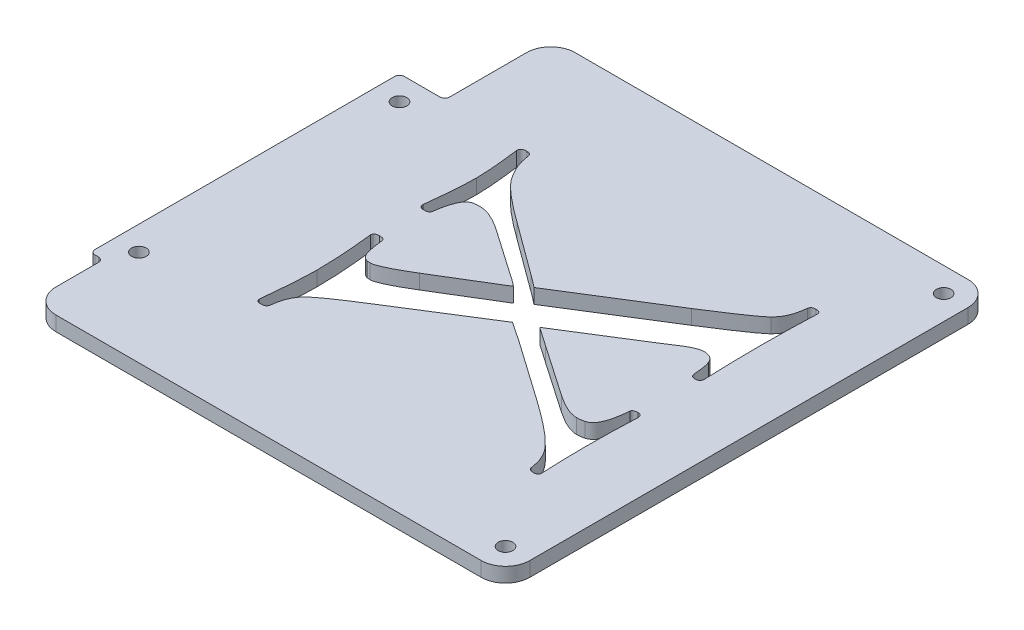
from build123d import *

# Parameters (mm, degrees)
BOSS_EXTRUDE1_DEPTH = 3
FILLET3_R           = 5
FILLET2_R           = 1
SKETCH2_R           = 1.5
CUT_EXTRUDE1_DEPTH  = 3
CUT_EXTRUDE2_DEPTH  = 3


with BuildPart() as part:
    # Sketch1 → Boss-Extrude1 (new body)
    with BuildSketch(Plane(origin=(0, 23, 0), x_dir=(1, 0, 0), z_dir=(0, 1, 0))):
        Polygon((98.305417602, 50), (98.305417602, 28.219474586), (89, 28.219474586), (89, -35.308001182), (91.659783805, -35.308001182), (91.659783805, -50), (97.650210801, -50), (189, -50), (189, 50), align=None)
    extrude(amount=BOSS_EXTRUDE1_DEPTH)

    # Fillet3
    fillet3_edges = [part.edges().sort_by_distance(p)[0] for p in [
        (189, 24.5, 50),
        (91.659783805, 24.5, 50),
        (98.305417602, 24.5, -50),
        (189, 24.5, -50),
    ]]
    fillet(fillet3_edges, radius=FILLET3_R)

    # Fillet2
    fillet2_edges = [part.edges().sort_by_distance(p)[0] for p in [
        (91.659783805, 24.5, 35.308001182),
        (89, 24.5, 35.308001182),
        (89, 24.5, -28.219474586),
        (98.305417602, 24.5, -28.219474586),
    ]]
    fillet(fillet2_edges, radius=FILLET2_R)

    # Sketch2 → Cut-Extrude1 (cut)
    with BuildSketch(Plane(origin=(0, 23, 0), x_dir=(1, 0, 0), z_dir=(0, 1, 0))):
        with Locations((184, -45)):
            Circle(SKETCH2_R)
        with Locations((94, -30.308001182)):
            Circle(SKETCH2_R)
        with Locations((94, 23.219474586)):
            Circle(SKETCH2_R)
        with Locations((184, 45)):
            Circle(SKETCH2_R)
    extrude(amount=CUT_EXTRUDE1_DEPTH, mode=Mode.SUBTRACT)

    # Sketch4 → Cut-Extrude2 (cut)
    with BuildSketch(Plane(origin=(0, 23, 0), x_dir=(1, 0, 0), z_dir=(0, 1, 0))):
        with BuildLine():
            Line((144.836538462, -4.405002967), (127.949519231, -15.042022198))
            add(Edge.make_bspline(
                [(127.949519231, -15.042022198), (127.383127553, -15.392246735), (126.301581574, -16.061013517), (124.782941164, -17.050886016), (123.413502397, -17.937550274), (122.221392395, -18.755591493), (121.177972607, -19.471486976), (120.314913735, -20.120669627), (119.610681433, -20.683215798), (119.210091774, -21.045947399), (119.03125, -21.207887583)],
                knots=[0, 0, 0, 0, 0.001997689, 0.003814661, 0.005438147, 0.006891629, 0.008151988, 0.009233719, 0.010130985, 0.010854638, 0.010854638, 0.010854638, 0.010854638], degree=3))
            add(Edge.make_bspline(
                [(119.03125, -21.207887583), (118.748201115, -21.52191014), (118.168801385, -22.164712831), (117.5545606, -23.367577881), (117.096940223, -24.745013365), (116.970362975, -25.743352665), (116.903846154, -26.267983736)],
                knots=[0, 0, 0, 0, 0.001263449, 0.002586275, 0.004015401, 0.005598156, 0.005598156, 0.005598156, 0.005598156], degree=3))
            add(Edge.make_bspline(
                [(116.903846154, -26.267983736), (116.872872765, -26.380485447), (116.813744298, -26.595252187), (116.565778181, -26.857180094), (116.195478928, -26.9748707), (115.922777734, -26.991879637), (115.774038462, -27.001156813)],
                knots=[0, 0, 0, 0, 0.000346062, 0.000660635, 0.001033425, 0.001480728, 0.001480728, 0.001480728, 0.001480728], degree=3))
            add(Edge.make_bspline(
                [(115.774038462, -27.001156813), (115.615840619, -26.999292557), (115.335974003, -26.995994514), (114.986148077, -26.864071662), (114.727918889, -26.653061509), (114.704405221, -26.454352171), (114.692307692, -26.352118352)],
                knots=[0, 0, 0, 0, 0.000470135, 0.000831712, 0.001112304, 0.001409643, 0.001409643, 0.001409643, 0.001409643], degree=3))
            add(Edge.make_bspline(
                [(114.692307692, -26.352118352), (114.753110505, -25.731192556), (114.869978219, -24.537725092), (115.027629344, -22.811043643), (115.159831841, -21.216431706), (115.268078948, -19.754038379), (115.353651644, -18.427912295), (115.414445517, -17.23393227), (115.453050203, -16.172085521), (115.458849243, -15.506792147), (115.461538462, -15.198272198)],
                knots=[0, 0, 0, 0, 0.001871684, 0.003597522, 0.005201538, 0.006671868, 0.007996658, 0.009188078, 0.010258397, 0.011183956, 0.011183956, 0.011183956, 0.011183956], degree=3))
            add(Edge.make_bspline(
                [(115.461538462, -15.198272198), (115.451286198, -14.352743878), (115.429651229, -12.568457125), (115.273718397, -9.755087799), (115.034984439, -6.665181967), (114.809821171, -4.516691888), (114.692307692, -3.395387583)],
                knots=[0, 0, 0, 0, 0.002536513, 0.005352709, 0.008450991, 0.011833161, 0.011833161, 0.011833161, 0.011833161], degree=3))
            add(Edge.make_bspline(
                [(114.692307692, -3.395387583), (114.704437153, -3.282548355), (114.727747275, -3.065696499), (114.970876174, -2.807073443), (115.342975667, -2.682888604), (115.624840109, -2.669736878), (115.786057692, -2.662214506)],
                knots=[0, 0, 0, 0, 0.000332435, 0.000638867, 0.001000444, 0.001483611, 0.001483611, 0.001483611, 0.001483611], degree=3))
            add(Edge.make_bspline(
                [(115.786057692, -2.662214506), (115.939656908, -2.666597614), (116.211768647, -2.674362596), (116.561756556, -2.781865744), (116.832507103, -2.95469515), (116.896246922, -3.136752797), (116.927884615, -3.227118352)],
                knots=[0, 0, 0, 0, 0.000458152, 0.000811648, 0.001095312, 0.001374872, 0.001374872, 0.001374872, 0.001374872], degree=3))
            add(Edge.make_bspline(
                [(116.927884615, -3.227118352), (116.982849031, -3.671982018), (117.082001591, -4.474489789), (117.23002735, -5.551059507), (117.388710401, -6.367065066), (117.522406295, -6.817488836), (117.576923077, -7.001156813)],
                knots=[0, 0, 0, 0, 0.001344704, 0.002425767, 0.003260217, 0.003834756, 0.003834756, 0.003834756, 0.003834756], degree=3))
            add(Edge.make_bspline(
                [(117.576923077, -7.001156813), (117.648507033, -7.178202401), (117.785626495, -7.517334195), (118.122152571, -7.934591169), (118.528360995, -8.253438433), (118.846637322, -8.363764981), (119.007211538, -8.419426044)],
                knots=[0, 0, 0, 0, 0.000569995, 0.001091829, 0.001589431, 0.002096096, 0.002096096, 0.002096096, 0.002096096], degree=3))
            add(Edge.make_bspline(
                [(119.007211538, -8.419426044), (119.115236434, -8.43344845), (119.330699129, -8.461417053), (119.547930348, -8.465478018), (119.65625, -8.467502967)],
                knots=[0, 0, 0, 0, 0.000326516, 0.000651258, 0.000651258, 0.000651258, 0.000651258], degree=3))
            add(Edge.make_bspline(
                [(119.65625, -8.467502967), (119.80138086, -8.45638107), (120.138041343, -8.430581573), (120.689465078, -8.250909029), (121.366329192, -8.002753917), (122.154525275, -7.626516985), (123.087681364, -7.193065113), (124.124218267, -6.616881611), (125.29176971, -5.958831664), (126.103552637, -5.476455961), (126.53125, -5.222310659)],
                knots=[0, 0, 0, 0, 0.000435355, 0.001009894, 0.001728741, 0.002600114, 0.003626897, 0.004815404, 0.006155643, 0.007648061, 0.007648061, 0.007648061, 0.007648061], degree=3))
            Line((126.53125, -5.222310659), (138.538461538, 2.085381648))
            add(Edge.make_bspline(
                [(138.538461538, 2.085381648), (138.110471753, 2.428371758), (137.194007507, 3.162824268), (136.212856357, 3.808529268), (135.689903846, 4.152689341)],
                knots=[0, 0, 0, 0, 0.001644484, 0.00352137, 0.00352137, 0.00352137, 0.00352137], degree=3))
            Line((135.689903846, 4.152689341), (126.206730769, 10.727208571))
            add(Edge.make_bspline(
                [(126.206730769, 10.727208571), (125.695873286, 11.050460946), (124.745448532, 11.651855797), (123.335727312, 12.333795342), (122.065583026, 12.770656194), (121.253420745, 12.836525319), (120.882211538, 12.866631648)],
                knots=[0, 0, 0, 0, 0.001811877, 0.003370906, 0.004693786, 0.005807431, 0.005807431, 0.005807431, 0.005807431], degree=3))
            add(Edge.make_bspline(
                [(120.882211538, 12.866631648), (120.65322679, 12.860419876), (120.172300681, 12.847373578), (119.699570737, 12.75747602), (119.451923077, 12.710381648)],
                knots=[0, 0, 0, 0, 0.000686044, 0.001440867, 0.001440867, 0.001440867, 0.001440867], degree=3))
            add(Edge.make_bspline(
                [(119.451923077, 12.710381648), (119.299807708, 12.64937105), (118.980247873, 12.521201642), (118.553357151, 12.167626018), (118.182630845, 11.674411308), (117.861509743, 11.043719136), (117.564789055, 10.286993292), (117.300047417, 9.391108691), (117.09079131, 8.35647488), (116.984153061, 7.618833988), (116.927884615, 7.229612417)],
                knots=[0, 0, 0, 0, 0.000489406, 0.00102813, 0.001636379, 0.002329963, 0.003144615, 0.004072512, 0.005128564, 0.006308287, 0.006308287, 0.006308287, 0.006308287], degree=3))
            add(Edge.make_bspline(
                [(116.927884615, 7.229612417), (116.901872489, 7.112745653), (116.852062547, 6.888960539), (116.610235786, 6.629167127), (116.269746741, 6.478578705), (116.012237425, 6.466850862), (115.870192308, 6.460381648)],
                knots=[0, 0, 0, 0, 0.000353496, 0.000676901, 0.001021079, 0.00144449, 0.00144449, 0.00144449, 0.00144449], degree=3))
            add(Edge.make_bspline(
                [(115.870192308, 6.460381648), (115.695328233, 6.463299781), (115.386414272, 6.468454939), (114.993265039, 6.645053538), (114.721020008, 6.934658897), (114.702138587, 7.183949923), (114.692307692, 7.313747033)],
                knots=[0, 0, 0, 0, 0.000519058, 0.000916966, 0.001266351, 0.001645862, 0.001645862, 0.001645862, 0.001645862], degree=3))
            add(Edge.make_bspline(
                [(114.692307692, 7.313747033), (114.753349078, 7.854508859), (114.871761588, 8.903517889), (115.028776168, 10.433970874), (115.160140859, 11.86842069), (115.269619425, 13.206542418), (115.354496528, 14.444607976), (115.414901751, 15.586548033), (115.453615309, 16.632388141), (115.458984116, 17.297692402), (115.461538462, 17.614227802)],
                knots=[0, 0, 0, 0, 0.001632581, 0.003167, 0.004615355, 0.005953868, 0.007194704, 0.008338111, 0.009384406, 0.010334001, 0.010334001, 0.010334001, 0.010334001], degree=3))
            add(Edge.make_bspline(
                [(115.461538462, 17.614227802), (115.45893556, 17.874678434), (115.453407278, 18.427847421), (115.414472387, 19.305427434), (115.354006311, 20.279095234), (115.269072316, 21.34888522), (115.15943248, 22.518702864), (115.028373847, 23.784925284), (114.870231921, 25.150965033), (114.753128782, 26.091880692), (114.692307692, 26.580573956)],
                knots=[0, 0, 0, 0, 0.000781342, 0.001659487, 0.002634898, 0.003707913, 0.004878786, 0.006159666, 0.007526797, 0.009004185, 0.009004185, 0.009004185, 0.009004185], degree=3))
            add(Edge.make_bspline(
                [(114.692307692, 26.580573956), (114.702509868, 26.721020585), (114.721990872, 26.989202725), (114.978605259, 27.322573749), (115.389116261, 27.494156335), (115.696188965, 27.509423045), (115.870192308, 27.518073956)],
                knots=[0, 0, 0, 0, 0.000414968, 0.00079238, 0.001190287, 0.001710596, 0.001710596, 0.001710596, 0.001710596], degree=3))
            add(Edge.make_bspline(
                [(115.870192308, 27.518073956), (116.011883571, 27.507387883), (116.275462267, 27.487509301), (116.637972816, 27.316869106), (116.853037271, 26.978814056), (116.893940076, 26.719548958), (116.915865385, 26.580573956)],
                knots=[0, 0, 0, 0, 0.000424944, 0.000790495, 0.001153865, 0.001573679, 0.001573679, 0.001573679, 0.001573679], degree=3))
            add(Edge.make_bspline(
                [(116.915865385, 26.580573956), (117.001281169, 26.08799141), (117.176295173, 25.078706715), (117.734892637, 23.58987962), (118.487877879, 22.073780289), (119.154299543, 21.115918163), (119.5, 20.619035494)],
                knots=[0, 0, 0, 0, 0.001496817, 0.003066926, 0.00474936, 0.006562831, 0.006562831, 0.006562831, 0.006562831], degree=3))
            add(Edge.make_bspline(
                [(119.5, 20.619035494), (119.677478367, 20.408141742), (120.057531979, 19.956532155), (120.73372047, 19.284099273), (121.51907404, 18.541873374), (122.443997138, 17.748043668), (123.486635789, 16.882553452), (124.661279522, 15.961198449), (125.966699477, 14.989096948), (126.875455044, 14.32048406), (127.348557692, 13.972400879)],
                knots=[0, 0, 0, 0, 0.000826535, 0.001769949, 0.002858337, 0.004068166, 0.005425488, 0.006923463, 0.008546059, 0.010308137, 0.010308137, 0.010308137, 0.010308137], degree=3))
            Line((127.348557692, 13.972400879), (138.141826923, 6.051727802))
            add(Edge.make_bspline(
                [(138.141826923, 6.051727802), (138.573726766, 5.743444252), (139.497712665, 5.083917146), (140.377569534, 4.366496146), (140.846153846, 3.98442011)],
                knots=[0, 0, 0, 0, 0.001591493, 0.003404765, 0.003404765, 0.003404765, 0.003404765], degree=3))
            Line((140.846153846, 3.98442011), (160.774038462, 16.436343187))
            add(Edge.make_bspline(
                [(160.774038462, 16.436343187), (161.423572659, 16.852246648), (162.656151068, 17.641479346), (164.397698299, 18.773176707), (165.940071931, 19.775082238), (167.255263967, 20.678996589), (168.366026365, 21.445268828), (169.262782898, 22.094547837), (169.946295257, 22.630622941), (170.32618387, 22.957744074), (170.485576923, 23.094997033)],
                knots=[0, 0, 0, 0, 0.002313819, 0.004390782, 0.006230942, 0.007831125, 0.009178138, 0.010279194, 0.011152058, 0.011783039, 0.011783039, 0.011783039, 0.011783039], degree=3))
            add(Edge.make_bspline(
                [(170.485576923, 23.094997033), (170.776838011, 23.429099085), (171.369405188, 24.108825688), (172.003193088, 25.364560381), (172.452749205, 26.798429222), (172.581625507, 27.831209773), (172.649038462, 28.371439341)],
                knots=[0, 0, 0, 0, 0.001325226, 0.002696156, 0.004182513, 0.005812747, 0.005812747, 0.005812747, 0.005812747], degree=3))
            add(Edge.make_bspline(
                [(172.649038462, 28.371439341), (172.671748766, 28.479616779), (172.715743585, 28.689180106), (172.947424692, 28.94454591), (173.295923022, 29.067591071), (173.553677557, 29.083751037), (173.694711538, 29.092593187)],
                knots=[0, 0, 0, 0, 0.000326958, 0.00063339, 0.000983808, 0.001407219, 0.001407219, 0.001407219, 0.001407219], degree=3))
            add(Edge.make_bspline(
                [(173.694711538, 29.092593187), (173.840069372, 29.084747589), (174.098719582, 29.070787107), (174.442219482, 28.943800376), (174.6668533, 28.68939339), (174.683644356, 28.479654173), (174.692307692, 28.371439341)],
                knots=[0, 0, 0, 0, 0.000435355, 0.000774672, 0.001073224, 0.00139145, 0.00139145, 0.00139145, 0.00139145], degree=3))
            add(Edge.make_bspline(
                [(174.692307692, 28.371439341), (174.622199026, 26.488640924), (174.4838024, 22.771939943), (174.462455908, 19.052732497), (174.451923077, 17.217593187)],
                knots=[0, 0, 0, 0, 0.005651915, 0.01115705, 0.01115705, 0.01115705, 0.01115705], degree=3))
            add(Edge.make_bspline(
                [(174.451923077, 17.217593187), (174.45288042, 16.147853356), (174.454755771, 14.052327372), (174.509057658, 10.975395797), (174.57341806, 8.026167011), (174.653226281, 6.103713808), (174.692307692, 5.162304725)],
                knots=[0, 0, 0, 0, 0.003209157, 0.006286456, 0.00923205, 0.01205864, 0.01205864, 0.01205864, 0.01205864], degree=3))
            add(Edge.make_bspline(
                [(174.692307692, 5.162304725), (174.684303973, 5.023524385), (174.669708769, 4.770451143), (174.471698218, 4.435734937), (174.12077465, 4.26560836), (173.860546407, 4.246976381), (173.71875, 4.236823956)],
                knots=[0, 0, 0, 0, 0.000413049, 0.000753217, 0.00110814, 0.001533084, 0.001533084, 0.001533084, 0.001533084], degree=3))
            add(Edge.make_bspline(
                [(173.71875, 4.236823956), (173.581137036, 4.244489073), (173.333733523, 4.258269583), (173.002976904, 4.392407183), (172.775664507, 4.63976824), (172.73178526, 4.849640758), (172.709134615, 4.957977802)],
                knots=[0, 0, 0, 0, 0.000411472, 0.000739753, 0.001046185, 0.001373143, 0.001373143, 0.001373143, 0.001373143], degree=3))
            add(Edge.make_bspline(
                [(172.709134615, 4.957977802), (172.671562771, 5.366931637), (172.602934133, 6.113925713), (172.47622601, 7.121354648), (172.333638542, 7.908193033), (172.191830142, 8.344330089), (172.132211538, 8.527689341)],
                knots=[0, 0, 0, 0, 0.001231839, 0.002250075, 0.003046796, 0.00362472, 0.00362472, 0.00362472, 0.00362472], degree=3))
            add(Edge.make_bspline(
                [(172.132211538, 8.527689341), (172.054577597, 8.695739423), (171.906140714, 9.017052885), (171.585101354, 9.425821246), (171.196180583, 9.740534172), (170.890340376, 9.853583429), (170.737980769, 9.909900879)],
                knots=[0, 0, 0, 0, 0.000553668, 0.001058619, 0.001546694, 0.002031205, 0.002031205, 0.002031205, 0.002031205], degree=3))
            add(Edge.make_bspline(
                [(170.737980769, 9.909900879), (170.583160062, 9.962015773), (170.278892016, 10.064436807), (169.958062571, 10.073646557), (169.800480769, 10.07817011)],
                knots=[0, 0, 0, 0, 0.000487038, 0.000957173, 0.000957173, 0.000957173, 0.000957173], degree=3))
            add(Edge.make_bspline(
                [(169.800480769, 10.07817011), (169.590777553, 10.061561831), (169.126280409, 10.024774135), (168.398643449, 9.78543657), (167.566836383, 9.434566033), (167.004607073, 9.111598262), (166.699519231, 8.936343187)],
                knots=[0, 0, 0, 0, 0.000629147, 0.001393574, 0.002282103, 0.003336307, 0.003336307, 0.003336307, 0.003336307], degree=3))
            add(Edge.make_bspline(
                [(166.699519231, 8.936343187), (166.642913551, 8.90512432), (166.497705966, 8.825040196), (166.254026368, 8.650851989), (165.910038324, 8.435902647), (165.474690816, 8.159512534), (164.953268876, 7.807514874), (164.325289872, 7.417701763), (163.617557451, 6.958764641), (163.117708771, 6.632778424), (162.853365385, 6.460381648)],
                knots=[0, 0, 0, 0, 0.000193804, 0.000497156, 0.000897236, 0.001410697, 0.002044078, 0.00278431, 0.0036278, 0.004574577, 0.004574577, 0.004574577, 0.004574577], degree=3))
            Line((162.853365385, 6.460381648), (148.538461538, -2.505964506))
            add(Edge.make_bspline(
                [(148.538461538, -2.505964506), (148.787552728, -2.66919637), (149.337817771, -3.029790373), (150.21557058, -3.64033589), (151.232362329, -4.354657877), (151.952149665, -4.86541557), (152.336538462, -5.138176044)],
                knots=[0, 0, 0, 0, 0.000893394, 0.001973587, 0.00320736, 0.004621345, 0.004621345, 0.004621345, 0.004621345], degree=3))
            Line((152.336538462, -5.138176044), (162.853365385, -12.361733736))
            add(Edge.make_bspline(
                [(162.853365385, -12.361733736), (163.14077554, -12.551690793), (163.690749188, -12.915183082), (164.501223444, -13.41357692), (165.263941393, -13.838873723), (165.990153326, -14.165173433), (166.648467109, -14.4638541), (167.279920247, -14.630385225), (167.855417197, -14.76950977), (168.229232993, -14.783156208), (168.40625, -14.789618352)],
                knots=[0, 0, 0, 0, 0.001033444, 0.001977547, 0.002854292, 0.003650107, 0.004366638, 0.005017122, 0.005606432, 0.006136506, 0.006136506, 0.006136506, 0.006136506], degree=3))
            add(Edge.make_bspline(
                [(168.40625, -14.789618352), (168.639475668, -14.780111116), (169.146491433, -14.759443072), (169.641401087, -14.646357819), (169.908653846, -14.585291429)],
                knots=[0, 0, 0, 0, 0.000698771, 0.001519078, 0.001519078, 0.001519078, 0.001519078], degree=3))
            add(Edge.make_bspline(
                [(169.908653846, -14.585291429), (170.09841482, -14.51952393), (170.486477994, -14.38502871), (170.9912696, -13.96726778), (171.444894942, -13.403757767), (171.797715394, -12.655407087), (172.131599694, -11.766061833), (172.383845496, -10.703560346), (172.587183025, -9.478669158), (172.667000038, -8.604466368), (172.709134615, -8.142983736)],
                knots=[0, 0, 0, 0, 0.000598191, 0.001223306, 0.001932848, 0.002755266, 0.00369076, 0.004781005, 0.006023877, 0.007413593, 0.007413593, 0.007413593, 0.007413593], degree=3))
            add(Edge.make_bspline(
                [(172.709134615, -8.142983736), (172.731726835, -8.052619898), (172.777244346, -7.870560003), (173.038970584, -7.697597172), (173.376599331, -7.589987506), (173.641131748, -7.582383817), (173.790865385, -7.57807989)],
                knots=[0, 0, 0, 0, 0.000270099, 0.000544179, 0.000886253, 0.001332423, 0.001332423, 0.001332423, 0.001332423], degree=3))
            add(Edge.make_bspline(
                [(173.790865385, -7.57807989), (173.925592642, -7.586804218), (174.169007971, -7.602566695), (174.488591944, -7.787347656), (174.667020403, -8.114690478), (174.683303873, -8.36509912), (174.692307692, -8.503560659)],
                knots=[0, 0, 0, 0, 0.000401162, 0.000724789, 0.001058742, 0.001471791, 0.001471791, 0.001471791, 0.001471791], degree=3))
            add(Edge.make_bspline(
                [(174.692307692, -8.503560659), (174.653189725, -9.300720126), (174.572816816, -10.938587084), (174.508421059, -13.475262448), (174.454731341, -16.155573718), (174.452873956, -17.994714193), (174.451923077, -18.936252967)],
                knots=[0, 0, 0, 0, 0.002394272, 0.00491934, 0.007612077, 0.010436622, 0.010436622, 0.010436622, 0.010436622], degree=3))
            add(Edge.make_bspline(
                [(174.451923077, -18.936252967), (174.461271376, -20.531079435), (174.479668776, -23.669688694), (174.622200726, -26.805100564), (174.692307692, -28.347310659)],
                knots=[0, 0, 0, 0, 0.004784031, 0.009414946, 0.009414946, 0.009414946, 0.009414946], degree=3))
            add(Edge.make_bspline(
                [(174.692307692, -28.347310659), (174.68463338, -28.449218952), (174.669875742, -28.645187741), (174.427090205, -28.856444346), (174.097935191, -28.992407913), (173.833114868, -28.994921411), (173.682692308, -28.996349121)],
                knots=[0, 0, 0, 0, 0.000294655, 0.000566619, 0.000905936, 0.001352107, 0.001352107, 0.001352107, 0.001352107], degree=3))
            add(Edge.make_bspline(
                [(173.682692308, -28.996349121), (173.540770493, -28.99339545), (173.28106068, -28.987990381), (172.950279777, -28.856473725), (172.700573735, -28.645170348), (172.65876361, -28.449219631), (172.637019231, -28.347310659)],
                knots=[0, 0, 0, 0, 0.000422216, 0.000772633, 0.001053225, 0.00135729, 0.00135729, 0.00135729, 0.00135729], degree=3))
            add(Edge.make_bspline(
                [(172.637019231, -28.347310659), (172.550490094, -27.822045463), (172.381764341, -26.797815138), (171.832940758, -25.353206673), (171.078193215, -24.031922411), (170.403865457, -23.280375947), (170.064903846, -22.902599121)],
                knots=[0, 0, 0, 0, 0.001593444, 0.003107103, 0.004609892, 0.006128792, 0.006128792, 0.006128792, 0.006128792], degree=3))
            add(Edge.make_bspline(
                [(170.064903846, -22.902599121), (169.841971407, -22.676784401), (169.368113626, -22.196800141), (168.582218019, -21.463394298), (167.683111009, -20.670530128), (166.655692616, -19.831398828), (165.518567335, -18.932711021), (164.262448831, -17.981578444), (162.89238091, -16.97152959), (161.932845963, -16.286696208), (161.435096154, -15.931445275)],
                knots=[0, 0, 0, 0, 0.000951875, 0.002023273, 0.003224054, 0.004547534, 0.006002308, 0.007572049, 0.009274033, 0.011108571, 0.011108571, 0.011108571, 0.011108571], degree=3))
            Line((161.435096154, -15.931445275), (149.007211538, -7.205483736))
            add(Edge.make_bspline(
                [(149.007211538, -7.205483736), (148.711236338, -7.000424417), (148.085520501, -6.566912205), (147.088460691, -5.898916067), (145.998728721, -5.163691781), (145.23386321, -4.664380328), (144.836538462, -4.405002967)],
                knots=[0, 0, 0, 0, 0.001080194, 0.002283618, 0.003600369, 0.005023823, 0.005023823, 0.005023823, 0.005023823], degree=3))
        make_face()
    extrude(amount=CUT_EXTRUDE2_DEPTH, mode=Mode.SUBTRACT)


solid = part.part
